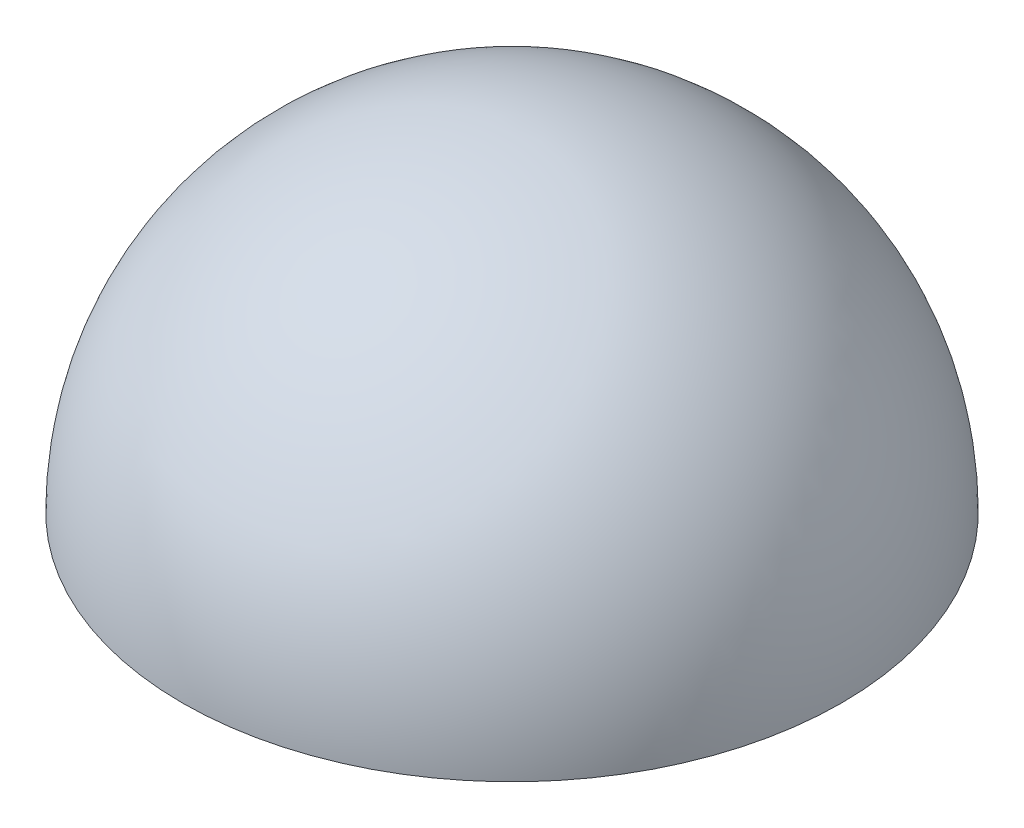
from build123d import *


with BuildPart() as part:
    # Sketch2 → Revolve1 (revolve)
    with BuildSketch(Plane.XY):
        with BuildLine():
            Line((0, 76.75), (0, 84.25))
            ThreePointArc((0, 84.25), (-59.573746315, 59.573746315), (-84.25, 0))
            Line((-84.25, 0), (-76.75, 0))
            ThreePointArc((-76.75, 0), (-54.270445456, 54.270445456), (0, 76.75))
        make_face()
    revolve(axis=Axis((0, 0, 0), (0, 1, 0)))


solid = part.part
